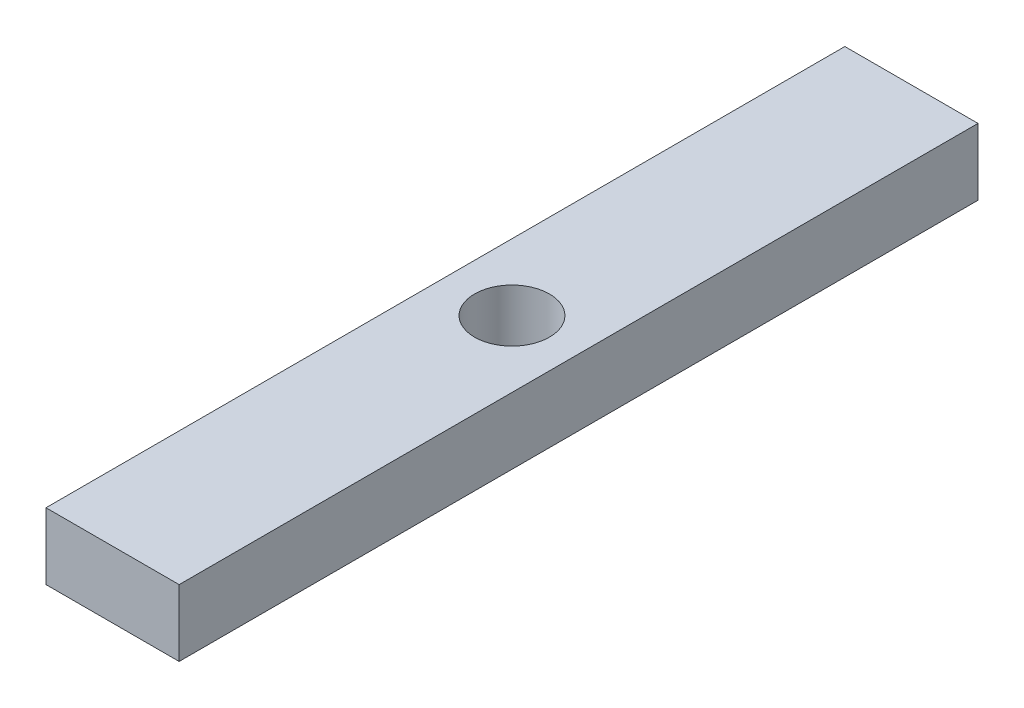
from build123d import *

# Parameters (mm, degrees)
SKETCH1_W           = 50.8
SKETCH1_H           = 304.8
SKETCH1_R           = 14.2875
BOSS_EXTRUDE1_DEPTH = 25.4


with BuildPart() as part:
    # Sketch1 → Boss-Extrude1 (new body)
    with BuildSketch(Plane(origin=(0, 0, 0), x_dir=(1, 0, 0), z_dir=(0, 1, 0))):
        with Locations((25.4, 152.4)):
            Rectangle(SKETCH1_W, SKETCH1_H)
        with Locations((25.4, 152.4)):
            Circle(SKETCH1_R, mode=Mode.SUBTRACT)
    extrude(amount=BOSS_EXTRUDE1_DEPTH)


solid = part.part
